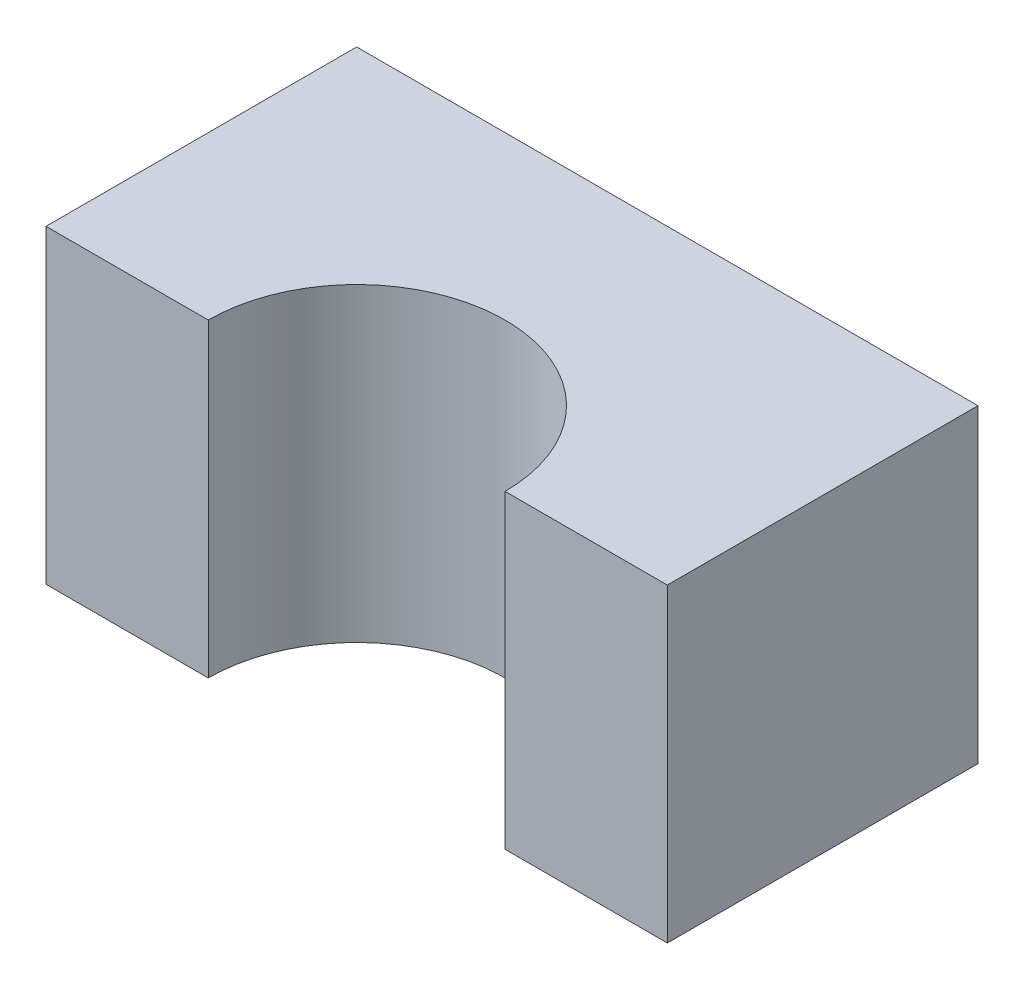
from build123d import *

# Parameters (mm, degrees)
SKETCH2_W               = 79.756
SKETCH2_H               = 39.795093556
BOSS_EXTRUDE1_DEPTH     = 39.878
SKETCH4_R               = 19.05
CUT_EXTRUDE2_DEPTH      = 1
CUT_EXTRUDE2_DEPTH_BACK = 40.795093555


with BuildPart() as part:
    # Sketch2 → Boss-Extrude1 (new body)
    with BuildSketch(Plane.XY):
        Rectangle(SKETCH2_W, SKETCH2_H)
    extrude(amount=-BOSS_EXTRUDE1_DEPTH)

    # Sketch4 → Cut-Extrude2 (cut, two sides)
    with BuildSketch(Plane(origin=(0, 19.897546778, 0), x_dir=(1, 0, 0), z_dir=(0, 1, 0))) as cut_extrude2_sk:
        Circle(SKETCH4_R)
    extrude(amount=CUT_EXTRUDE2_DEPTH, mode=Mode.SUBTRACT)
    extrude(cut_extrude2_sk.sketch, amount=-CUT_EXTRUDE2_DEPTH_BACK, mode=Mode.SUBTRACT)


solid = part.part
